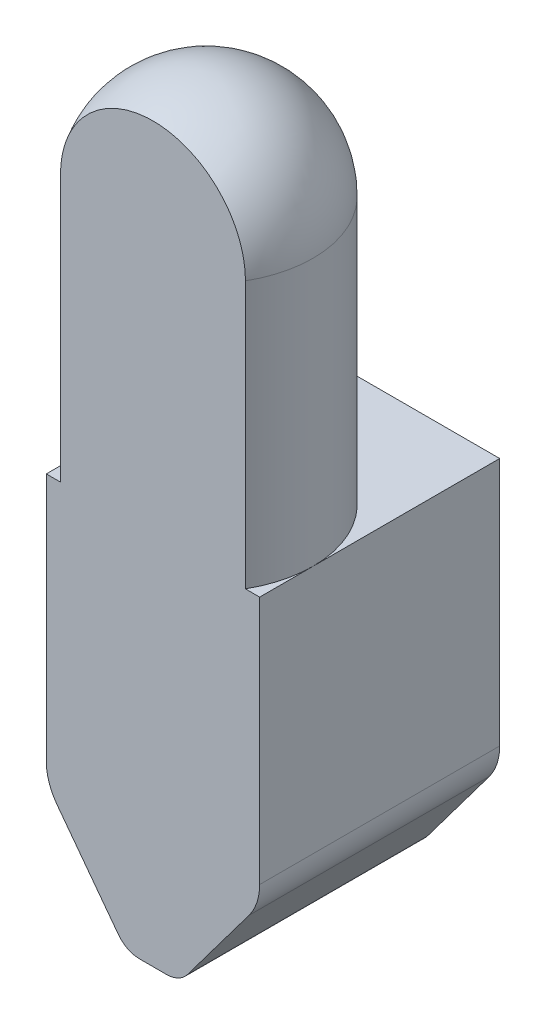
from build123d import *

# Parameters (mm, degrees)
EXTRUDE_1_DEPTH          = 4.5
EXTRUDE_2_DEPTH          = 5
SKETCH_4_W               = 4.107505073
SKETCH_4_H               = 2.274071006
CUT_EXTRUDE_1_DEPTH      = 13
CUT_EXTRUDE_1_DEPTH_BACK = 3
FILLET_1_R               = 1
FILLET_2_R               = 0.5


with BuildPart() as part:
    # Эскиз1 → Бобышка-Вытянуть1 (new body)
    with BuildSketch(Plane.XY):
        Polygon((2, 0), (2, 5), (-2, 5), (-2, 0), (-0.5, -2), (0.5, -2), align=None)
    extrude(amount=-EXTRUDE_1_DEPTH)

    # Эскиз2 → Бобышка-Вытянуть2 (add)
    with BuildSketch(Plane(origin=(0, 5, 0), x_dir=(1, 0, 0), z_dir=(0, 1, 0))):
        with BuildLine():
            Line((-1.732050808, 0), (1.732050808, 0))
            ThreePointArc((1.732050808, 0), (0, 3), (-1.732050808, 0))
        make_face()
    extrude(amount=EXTRUDE_2_DEPTH)

    # Эскиз3 → Повернуть1 (revolve)
    with BuildSketch(Plane(origin=(0, 10, 0), x_dir=(1, 0, 0), z_dir=(0, 1, 0))):
        with BuildLine():
            ThreePointArc((2, 1), (0, 3), (-2, 1))
            Line((-2, 1), (2, 1))
        make_face()
    revolve(axis=Axis((-2, 10, -1), (1, 0, 0)))

    # Эскиз4 → Вырез-Вытянуть1 (cut, two sides)
    with BuildSketch(Plane(origin=(0, 0, 0), x_dir=(1, 0, 0), z_dir=(0, 1, 0))) as cut_extrude_1_sk:
        with Locations((0.053752537, -1.137035503)):
            Rectangle(SKETCH_4_W, SKETCH_4_H)
    extrude(amount=CUT_EXTRUDE_1_DEPTH, mode=Mode.SUBTRACT)
    extrude(cut_extrude_1_sk.sketch, amount=-CUT_EXTRUDE_1_DEPTH_BACK, mode=Mode.SUBTRACT)

    # Скругление1
    fillet_1_edges = [part.edges().sort_by_distance(p)[0] for p in [
        (2, 0, -2.25),
        (-2, 0, -2.25),
    ]]
    fillet(fillet_1_edges, radius=FILLET_1_R)

    # Скругление2
    fillet_2_edges = [part.edges().sort_by_distance(p)[0] for p in [
        (0.5, -2, -2.25),
        (-0.5, -2, -2.25),
    ]]
    fillet(fillet_2_edges, radius=FILLET_2_R)


solid = part.part
